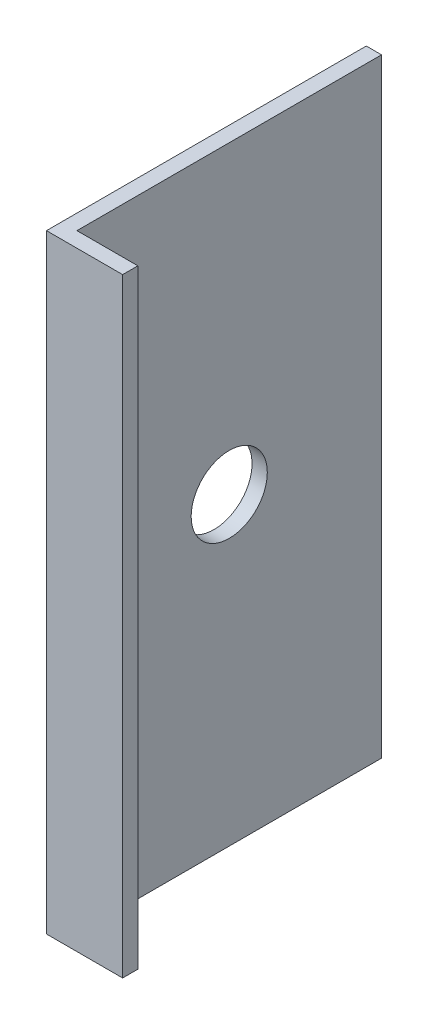
from build123d import *

# Parameters (mm, degrees)
EXTRUDE_1_DEPTH     = 80
SKETCH_3_R          = 5
CUT_EXTRUDE_1_DEPTH = 10


with BuildPart() as part:
    # Эскиз2 → Вытянуть-Тонкостенный1 (new body)
    with BuildSketch(Plane(origin=(0, 0, 0), x_dir=(1, 0, 0), z_dir=(0, 1, 0))):
        Polygon((0, 42), (0, 0), (10, 0), (10, 2), (2, 2), (2, 42), align=None)
    extrude(amount=EXTRUDE_1_DEPTH)

    # Эскиз3 → Вырез-Вытянуть1 (cut)
    with BuildSketch(Plane.ZY):
        with Locations((-22, 40)):
            Circle(SKETCH_3_R)
    extrude(amount=-CUT_EXTRUDE_1_DEPTH, mode=Mode.SUBTRACT)


solid = part.part
